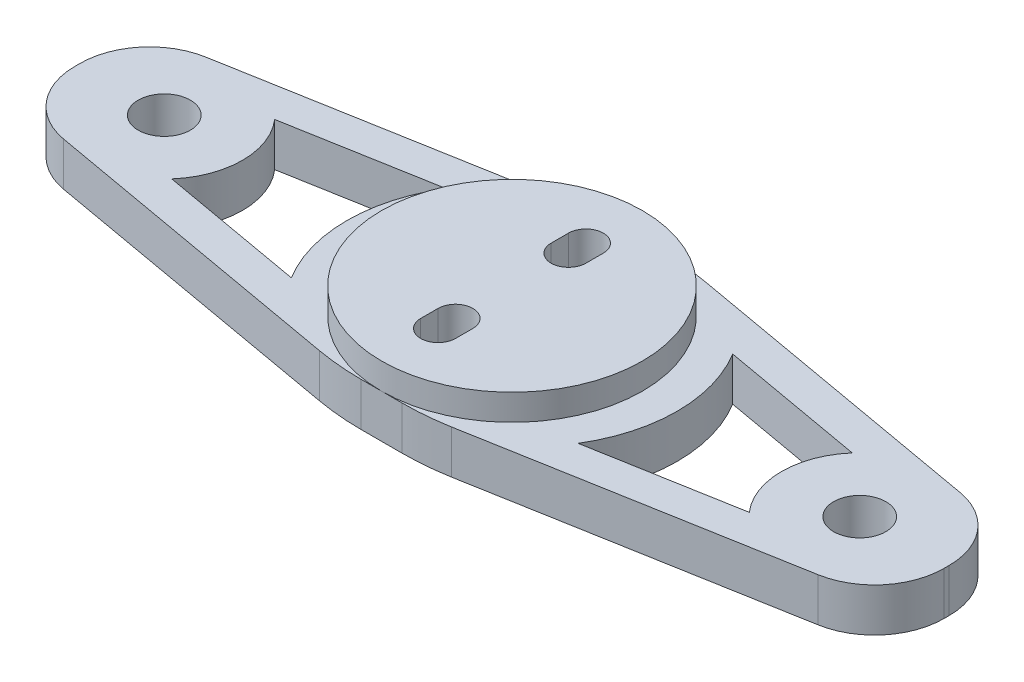
from build123d import *

# Parameters (mm, degrees)
SKETCH1_W           = 100
SKETCH1_H           = 30
BOSS_EXTRUDE1_DEPTH = 5
SKETCH2_R           = 15
BOSS_EXTRUDE2_DEPTH = 3
CUT_EXTRUDE1_DEPTH  = 9
SKETCH4_R           = 3
CUT_EXTRUDE2_DEPTH  = 6
CHAMFER1_SIZE       = 8
CHAMFER1_SIZE2      = 45
CHAMFER2_SIZE       = 45
CHAMFER2_SIZE2      = 8
CHAMFER3_SIZE       = 45
CHAMFER3_SIZE2      = 8
CHAMFER4_SIZE       = 8
CHAMFER4_SIZE2      = 45
FILLET1_R           = 8
CUT_EXTRUDE3_DEPTH  = 6
FILLET2_R           = 30
CUT_EXTRUDE4_DEPTH  = 3
FILLET3_R           = 0.5


with BuildPart() as part:
    # Sketch1 → Boss-Extrude1 (new body)
    with BuildSketch(Plane(origin=(0, 0, 0), x_dir=(1, 0, 0), z_dir=(0, 1, 0))):
        Rectangle(SKETCH1_W, SKETCH1_H)
    extrude(amount=BOSS_EXTRUDE1_DEPTH)

    # Sketch2 → Boss-Extrude2 (add)
    with BuildSketch(Plane(origin=(0, 5, 0), x_dir=(1, 0, 0), z_dir=(0, 1, 0))):
        Circle(SKETCH2_R)
    extrude(amount=BOSS_EXTRUDE2_DEPTH)

    # Sketch3 → Cut-Extrude1 (cut, through all)
    with BuildSketch(Plane(origin=(0, 8, 0), x_dir=(1, 0, 0), z_dir=(0, 1, 0))):
        with BuildLine():
            Line((-2, 6.5), (-2, 8.5))
            ThreePointArc((-2, 8.5), (0, 10.5), (2, 8.5))
            Line((2, 8.5), (2, 6.5))
            ThreePointArc((2, 6.5), (0, 4.5), (-2, 6.5))
        make_face()
        with BuildLine():
            Line((-2, -8.5), (-2, -6.5))
            ThreePointArc((-2, -6.5), (0, -4.5), (2, -6.5))
            Line((2, -6.5), (2, -8.5))
            ThreePointArc((2, -8.5), (0, -10.5), (-2, -8.5))
        make_face()
    extrude(amount=-CUT_EXTRUDE1_DEPTH, mode=Mode.SUBTRACT)

    # Sketch4 → Cut-Extrude2 (cut, through all)
    with BuildSketch(Plane(origin=(0, 5, 0), x_dir=(1, 0, 0), z_dir=(0, 1, 0))):
        with Locations((40, 0)):
            Circle(SKETCH4_R)
        with Locations((-40, 0)):
            Circle(SKETCH4_R)
    extrude(amount=-CUT_EXTRUDE2_DEPTH, mode=Mode.SUBTRACT)

    # Chamfer1
    chamfer1_edges = [part.edges().sort_by_distance(p)[0] for p in [
        (50, 2.5, -15),
    ]]
    chamfer1_side = [part.faces().sort_by_distance(p)[0] for p in [
        (50, 2.5, 0),
    ]]
    chamfer(chamfer1_edges, length=CHAMFER1_SIZE, length2=CHAMFER1_SIZE2, reference=chamfer1_side[0])

    # Chamfer2
    chamfer2_edges = [part.edges().sort_by_distance(p)[0] for p in [
        (50, 2.5, 15),
    ]]
    chamfer2_side = [part.faces().sort_by_distance(p)[0] for p in [
        (0, 2.5, 15),
    ]]
    chamfer(chamfer2_edges, length=CHAMFER2_SIZE, length2=CHAMFER2_SIZE2, reference=chamfer2_side[0])

    # Chamfer3
    chamfer3_edges = [part.edges().sort_by_distance(p)[0] for p in [
        (-50, 2.5, -15),
    ]]
    chamfer3_side = [part.faces().sort_by_distance(p)[0] for p in [
        (-22.5, 2.5, -15),
    ]]
    chamfer(chamfer3_edges, length=CHAMFER3_SIZE, length2=CHAMFER3_SIZE2, reference=chamfer3_side[0])

    # Chamfer4
    chamfer4_edges = [part.edges().sort_by_distance(p)[0] for p in [
        (-50, 2.5, 15),
    ]]
    chamfer4_side = [part.faces().sort_by_distance(p)[0] for p in [
        (-50, 2.5, 4),
    ]]
    chamfer(chamfer4_edges, length=CHAMFER4_SIZE, length2=CHAMFER4_SIZE2, reference=chamfer4_side[0])

    # Fillet1
    fillet1_edges = [part.edges().sort_by_distance(p)[0] for p in [
        (50, 2.5, -7),
        (50, 2.5, 7),
        (-50, 2.5, -7),
        (-50, 2.5, 7),
    ]]
    fillet(fillet1_edges, radius=FILLET1_R)

    # Sketch5 → Cut-Extrude3 (cut, through all)
    with BuildSketch(Plane(origin=(0, 5, 0), x_dir=(1, 0, 0), z_dir=(0, 1, 0))):
        with BuildLine():
            Line((-16.487122597, 8.895126691), (-33.221241877, 5.920172153))
            ThreePointArc((-33.221241877, 5.920172153), (-31, 0), (-33.221241877, -5.920172153))
            Line((-33.221241877, -5.920172153), (-16.487122597, -8.895126691))
            ThreePointArc((-16.487122597, -8.895126691), (-19, 0), (-16.487122597, 8.895126691))
        make_face()
    cut_extrude3 = extrude(amount=-CUT_EXTRUDE3_DEPTH, mode=Mode.SUBTRACT)

    # Mirror2: Cut-Extrude3 across plane
    add(cut_extrude3.mirror(Plane(origin=(0, 0, 0), x_dir=(0, 0, 1), z_dir=(1, 0, 0))), mode=Mode.SUBTRACT)

    # Fillet2
    fillet2_edges = [part.edges().sort_by_distance(p)[0] for p in [
        (5, 2.5, -15),
        (5, 2.5, 15),
        (-5, 2.5, -15),
        (-5, 2.5, 15),
    ]]
    fillet(fillet2_edges, radius=FILLET2_R)

    # Sketch7 → Cut-Extrude4 (cut)
    with BuildSketch(Plane.XZ):
        with BuildLine():
            Line((-4, 8.5), (-4, 6.5))
            ThreePointArc((-4, 6.5), (0, 2.5), (4, 6.5))
            Line((4, 6.5), (4, 8.5))
            ThreePointArc((4, 8.5), (0, 12.5), (-4, 8.5))
        make_face()
    cut_extrude4 = extrude(amount=-CUT_EXTRUDE4_DEPTH, mode=Mode.SUBTRACT)

    # Mirror3: Cut-Extrude4 across plane
    add(cut_extrude4.mirror(Plane.XY), mode=Mode.SUBTRACT)

    # Fillet3
    fillet3_edges = [part.edges().sort_by_distance(p)[0] for p in [
        (0, 0, 12.5),
        (-4, 0, 7.5),
        (0, 0, 2.5),
        (4, 0, 7.5),
        (0, 0, -12.5),
        (-4, 0, -7.5),
        (0, 0, -2.5),
        (4, 0, -7.5),
    ]]
    fillet(fillet3_edges, radius=FILLET3_R)


solid = part.part
